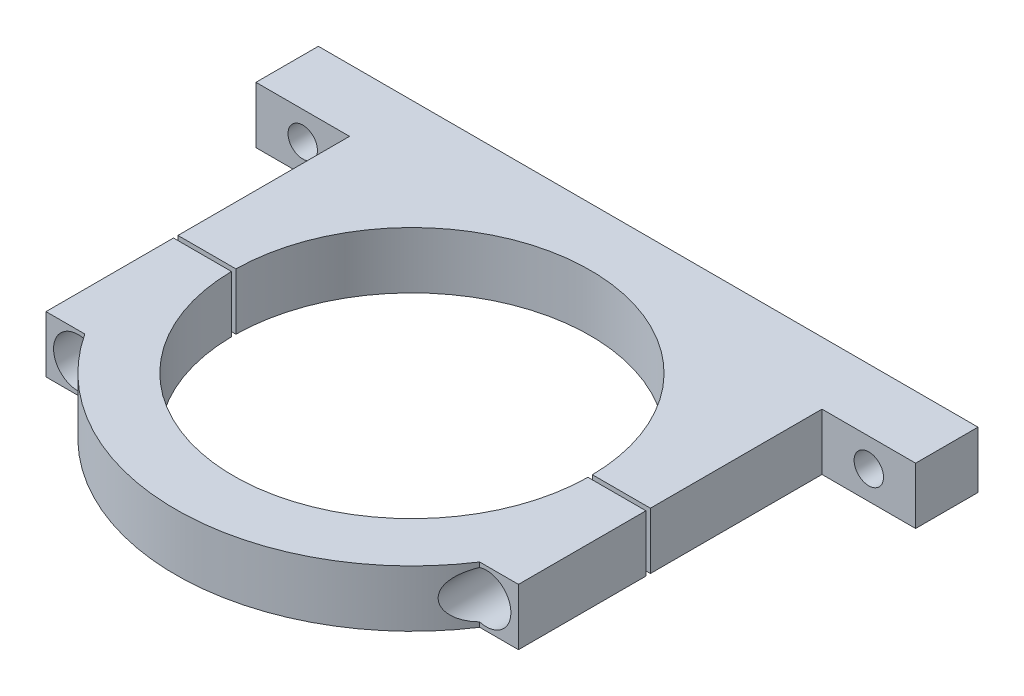
from build123d import *

# Parameters (mm, degrees)
SKETCH1_R               = 40
BOSS_EXTRUDE1_DEPTH     = 12.7
SKETCH3_R               = 3.3
CUT_EXTRUDE2_DEPTH      = 15
SKETCH4_R               = 3.3
CUT_EXTRUDE3_DEPTH      = 72.7
CUT_EXTRUDE3_DEPTH_BACK = 12.7
SKETCH2_W               = 153.705760516
SKETCH2_H               = 1
CUT_EXTRUDE1_DEPTH      = 1.0000001
CUT_EXTRUDE1_DEPTH_BACK = 13.7000001
CUT_EXTRUDE4_START      = 40
SKETCH5_R               = 5.5
CUT_EXTRUDE4_DEPTH      = 18.7


with BuildPart() as part:
    # Sketch1 → Boss-Extrude1 (new body)
    with BuildSketch(Plane(origin=(0, 0, 0), x_dir=(1, 0, 0), z_dir=(0, 1, 0))):
        with BuildLine():
            Line((-74, 53), (74, 53))
            Line((74, 53), (74, 39))
            Line((74, 39), (53, 39))
            Line((53, 39), (53, 0))
            Line((53, 0), (53, -29.1))
            Line((53, -29.1), (44.296613866, -29.1))
            ThreePointArc((44.296613866, -29.1), (0, -53), (-44.296613866, -29.1))
            Line((-44.296613866, -29.1), (-53, -29.1))
            Line((-53, -29.1), (-53, 0))
            Line((-53, 0), (-53, 39))
            Line((-53, 39), (-74, 39))
            Line((-74, 39), (-74, 53))
        make_face()
        Circle(SKETCH1_R, mode=Mode.SUBTRACT)
    extrude(amount=BOSS_EXTRUDE1_DEPTH)

    # Sketch3 → Cut-Extrude2 (cut, through all)
    with BuildSketch(Plane.XY.offset(-39)):
        with Locations((-63.5, 6.35)):
            Circle(SKETCH3_R)
        with Locations((63.5, 6.35)):
            Circle(SKETCH3_R)
    extrude(amount=-CUT_EXTRUDE2_DEPTH, mode=Mode.SUBTRACT)

    # Sketch4 → Cut-Extrude3 (cut, two sides)
    with BuildSketch(Plane.XY) as cut_extrude3_sk:
        with Locations((45.8, 6.35)):
            Circle(SKETCH4_R)
        with Locations((-45.8, 6.35)):
            Circle(SKETCH4_R)
    extrude(amount=CUT_EXTRUDE3_DEPTH, mode=Mode.SUBTRACT)
    extrude(cut_extrude3_sk.sketch, amount=-CUT_EXTRUDE3_DEPTH_BACK, mode=Mode.SUBTRACT)

    # Sketch2 → Cut-Extrude1 (cut, two sides)
    with BuildSketch(Plane(origin=(0, 12.7, 0), x_dir=(1, 0, 0), z_dir=(0, 1, 0))) as cut_extrude1_sk:
        Rectangle(SKETCH2_W, SKETCH2_H)
    extrude(amount=CUT_EXTRUDE1_DEPTH, mode=Mode.SUBTRACT)
    extrude(cut_extrude1_sk.sketch, amount=-CUT_EXTRUDE1_DEPTH_BACK, mode=Mode.SUBTRACT)

    # Sketch5 → Cut-Extrude4 (cut)
    with BuildSketch(Plane.XY.offset(CUT_EXTRUDE4_START)):
        with Locations((45.8, 6.35)):
            Circle(SKETCH5_R)
        with Locations((-45.8, 6.35)):
            Circle(SKETCH5_R)
    extrude(amount=-CUT_EXTRUDE4_DEPTH, mode=Mode.SUBTRACT)


solid = part.part
